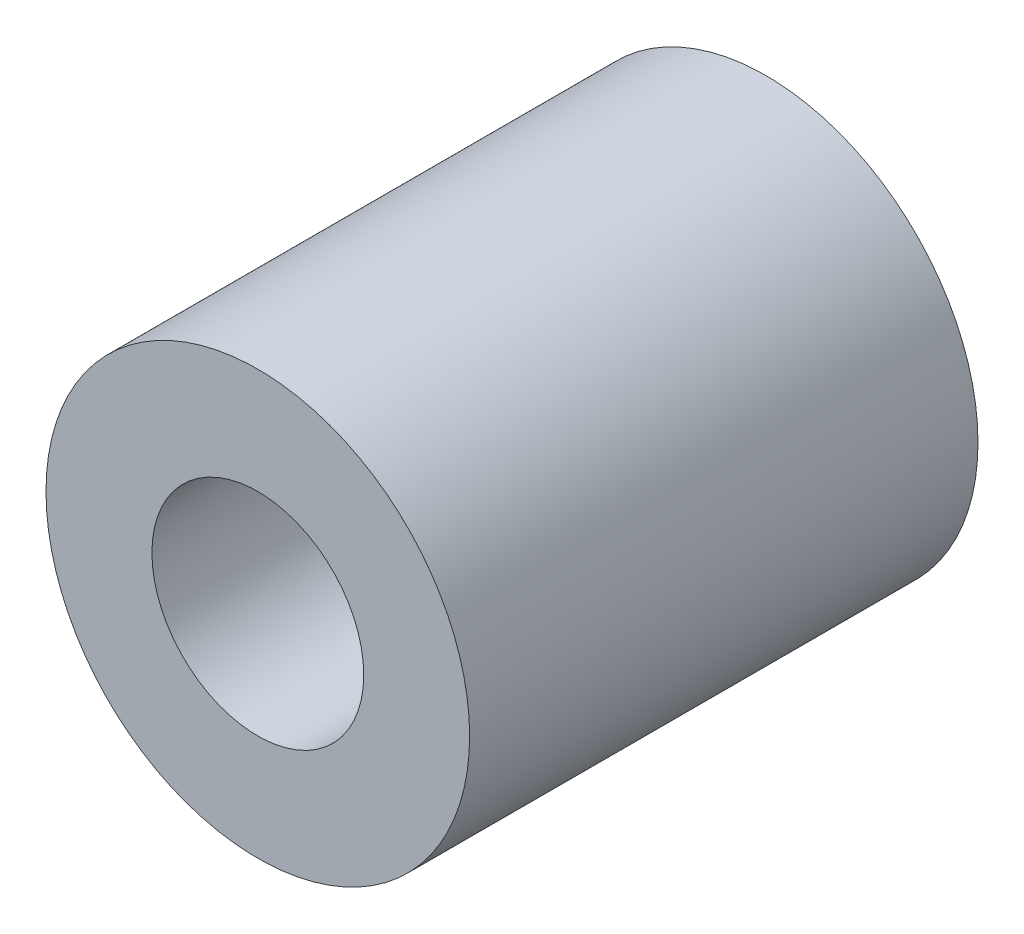
from build123d import *

# Parameters (mm, degrees)
ESQUISSE1_R      = 5
ESQUISSE1_R_2    = 2.5
EXTRUSION1_DEPTH = 12


with BuildPart() as part:
    # Esquisse1 → Extrusion1 (new body)
    with BuildSketch(Plane.XY):
        Circle(ESQUISSE1_R)
        Circle(ESQUISSE1_R_2, mode=Mode.SUBTRACT)
    extrude(amount=EXTRUSION1_DEPTH)


solid = part.part
